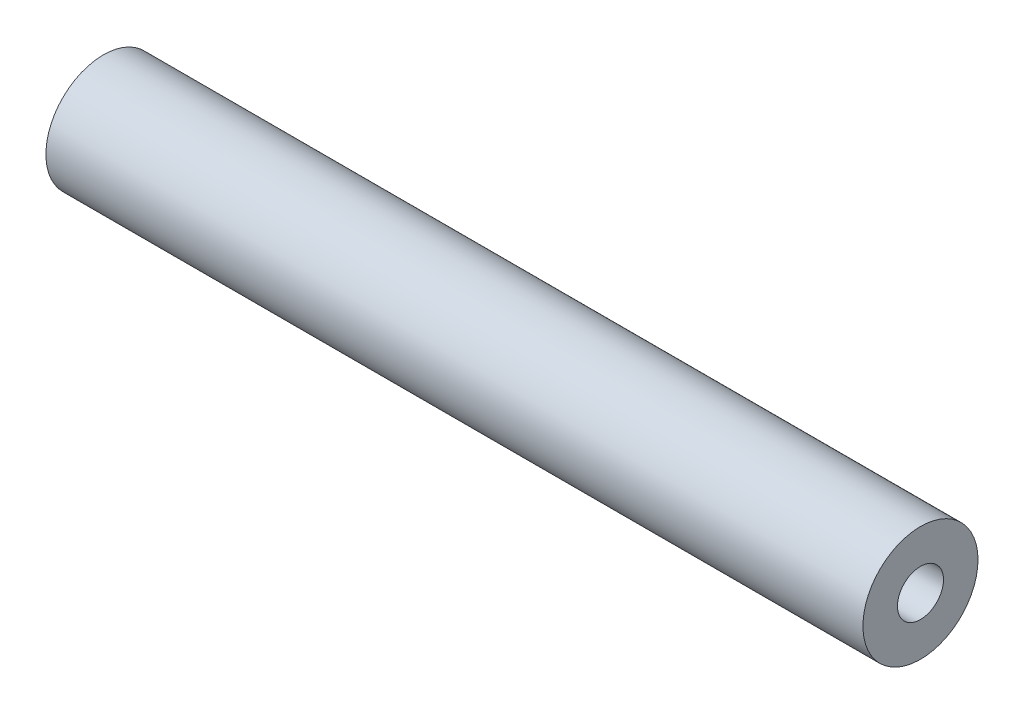
from build123d import *

# Parameters (mm, degrees)
SKETCH1_R           = 31.75
SKETCH1_R_2         = 12.7
BOSS_EXTRUDE1_DEPTH = 225.425


with BuildPart() as part:
    # Sketch1 → Boss-Extrude1 (new body, symmetric)
    with BuildSketch(Plane(origin=(0, 0, 0), x_dir=(0, 0, -1), z_dir=(1, 0, 0))):
        Circle(SKETCH1_R)
        Circle(SKETCH1_R_2, mode=Mode.SUBTRACT)
    extrude(amount=BOSS_EXTRUDE1_DEPTH, both=True)


solid = part.part
